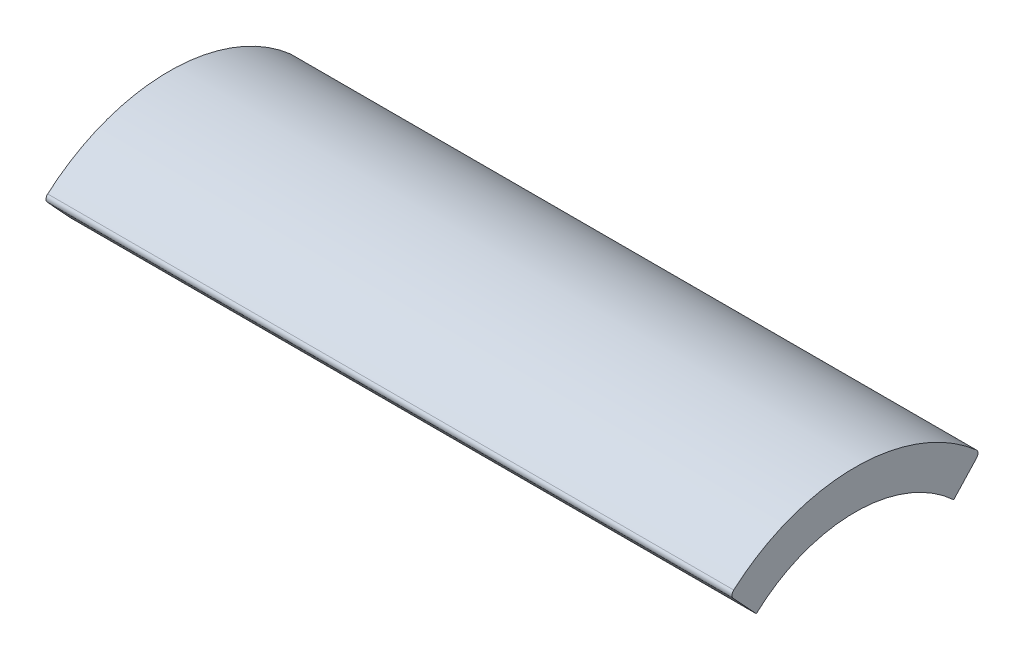
from build123d import *

# Parameters (mm, degrees)
BOSS_EXTRUDE1_DEPTH = 17.5


with BuildPart() as part:
    # Sketch1 → Boss-Extrude1 (new, symmetric)
    with BuildSketch(Plane(origin=(0, 0, 0), x_dir=(0, 0, -1), z_dir=(1, 0, 0))):
        with BuildLine():
            Line((-6.20870808, 6.716542561), (-5.036701532, 5.44867302))
            ThreePointArc((-5.036701532, 5.44867302), (0, 7.42), (5.036701532, 5.44867302))
            Line((5.036701532, 5.44867302), (6.20870808, 6.716542561))
            ThreePointArc((6.20870808, 6.716542561), (6.274777299, 6.899469771), (6.189748422, 7.074391456))
            ThreePointArc((6.189748422, 7.074391456), (0, 9.4), (-6.189748422, 7.074391456))
            ThreePointArc((-6.189748422, 7.074391456), (-6.274777299, 6.899469771), (-6.20870808, 6.716542561))
        make_face()
    extrude(amount=BOSS_EXTRUDE1_DEPTH, both=True)


solid = part.part
